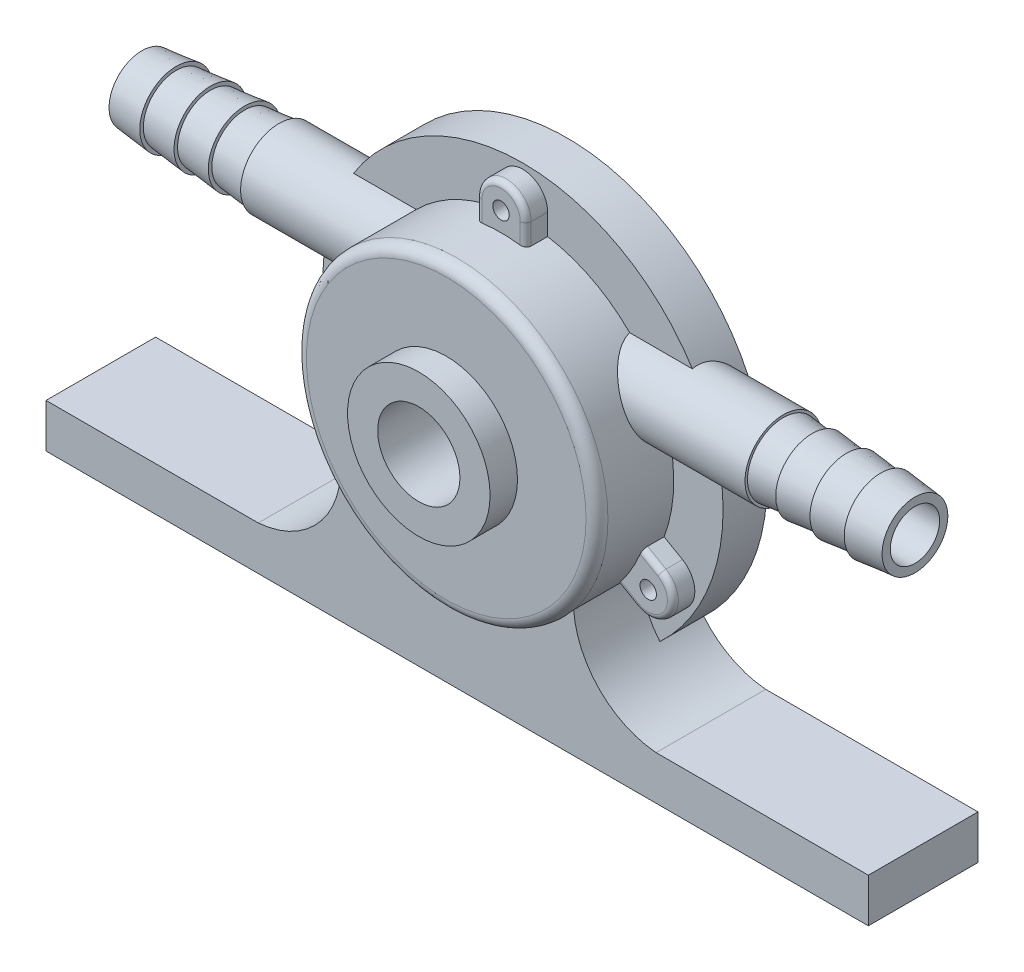
from build123d import *

# Parameters (mm, degrees)
SKETCH1_R                = 36.5
BOSS_EXTRUDE1_DEPTH      = 8
SKETCH2_R                = 27.5
BOSS_EXTRUDE2_DEPTH      = 14
SKETCH3_R                = 13
BOSS_EXTRUDE3_DEPTH      = 5
SKETCH4_R                = 7.5
CUT_EXTRUDE1_DEPTH       = 14
SKETCH6_R                = 7
BOSS_EXTRUDE4_DEPTH      = 10
BOSS_EXTRUDE4_DEPTH_BACK = 82
CUT_EXTRUDE2_DEPTH       = 12
SKETCH11_R               = 1.5
CUT_EXTRUDE4_DEPTH       = 28
FILLET1_R                = 2
SKETCH10_R               = 4.5
CUT_EXTRUDE5_DEPTH       = 93.0000001
SKETCH12_R               = 3.2
CUT_EXTRUDE6_DEPTH       = 14.0000001
SKETCH13_R               = 27.3
SKETCH13_R_2             = 25
CUT_EXTRUDE7_DEPTH       = 1.2
BOSS_EXTRUDE5_DEPTH      = 4
FILLET2_R                = 1
SKETCH15_R               = 1.5
CUT_EXTRUDE8_DEPTH       = 28
SKETCH16_W               = 25
SKETCH16_H               = 5.2
SKETCH17_R               = 4.5
CUT_EXTRUDE9_DEPTH       = 142
BOSS_EXTRUDE7_DEPTH      = 4
BOSS_EXTRUDE7_DEPTH_BACK = 16


with BuildPart() as part:
    # Sketch1 → Boss-Extrude1 (new body)
    with BuildSketch(Plane.XY):
        Circle(SKETCH1_R)
    extrude(amount=BOSS_EXTRUDE1_DEPTH)

    # Sketch2 → Boss-Extrude2 (add)
    with BuildSketch(Plane.XY.offset(8)):
        Circle(SKETCH2_R)
    extrude(amount=BOSS_EXTRUDE2_DEPTH)

    # Sketch3 → Boss-Extrude3 (add)
    with BuildSketch(Plane.XY.offset(22)):
        Circle(SKETCH3_R)
    extrude(amount=BOSS_EXTRUDE3_DEPTH)

    # Sketch4 → Cut-Extrude1 (cut)
    with BuildSketch(Plane.XY.offset(27)):
        Circle(SKETCH4_R)
    extrude(amount=-CUT_EXTRUDE1_DEPTH, mode=Mode.SUBTRACT)

    # Sketch6 → Boss-Extrude4 (add, two sides)
    with BuildSketch(Plane(origin=(36.5, 0, 0), x_dir=(0, 0, -1), z_dir=(1, 0, 0))) as boss_extrude4_sk:
        with Locations((-7, 12.5)):
            Circle(SKETCH6_R)
    extrude(amount=BOSS_EXTRUDE4_DEPTH)
    extrude(boss_extrude4_sk.sketch, amount=-BOSS_EXTRUDE4_DEPTH_BACK)

    # Sketch8 → Cut-Extrude2 (cut)
    with BuildSketch(Plane(origin=(0, 0, 0), x_dir=(-1, 0, 0), z_dir=(0, 0, -1))):
        with BuildLine():
            ThreePointArc((-17.653540721, 13.95), (0, -22.5), (17.653540721, 13.95))
            ThreePointArc((17.653540721, 13.95), (0, 18), (-17.653540721, 13.95))
        make_face()
    extrude(amount=-CUT_EXTRUDE2_DEPTH, mode=Mode.SUBTRACT)

    # Sketch11 → Cut-Extrude4 (cut, through all)
    with BuildSketch(Plane(origin=(0, 0, 0), x_dir=(-1, 0, 0), z_dir=(0, 0, -1))):
        with Locations((0, 31)):
            Circle(SKETCH11_R)
        with Locations((26.846787517, -15.5)):
            Circle(SKETCH11_R)
        with Locations((-26.846787517, -15.5)):
            Circle(SKETCH11_R)
    extrude(amount=-CUT_EXTRUDE4_DEPTH, mode=Mode.SUBTRACT)

    # Fillet1
    fillet1_edges = [part.edges().sort_by_distance(p)[0] for p in [
        (-27.5, 0, 22),
    ]]
    fillet(fillet1_edges, radius=FILLET1_R)

    # Sketch10 → Cut-Extrude5 (cut, through all)
    with BuildSketch(Plane(origin=(46.5, 0, 0), x_dir=(0, 0, -1), z_dir=(1, 0, 0))):
        with Locations((-7, 12.5)):
            Circle(SKETCH10_R)
    extrude(amount=-CUT_EXTRUDE5_DEPTH, mode=Mode.SUBTRACT)

    # Sketch12 → Cut-Extrude6 (cut, through all)
    with BuildSketch(Plane.XY.offset(13)):
        Circle(SKETCH12_R)
    extrude(amount=-CUT_EXTRUDE6_DEPTH, mode=Mode.SUBTRACT)

    # Sketch13 → Cut-Extrude7 (cut)
    with BuildSketch(Plane(origin=(0, 0, 0), x_dir=(-1, 0, 0), z_dir=(0, 0, -1))):
        Circle(SKETCH13_R)
        Circle(SKETCH13_R_2, mode=Mode.SUBTRACT)
    extrude(amount=-CUT_EXTRUDE7_DEPTH, mode=Mode.SUBTRACT)

    # Sketch14 → Boss-Extrude5 (add)
    with BuildSketch(Plane.XY.offset(8)):
        with BuildLine():
            Line((4.5, 31), (4.5, 27.129319933))
            ThreePointArc((4.5, 27.129319933), (0, 27.5), (-4.5, 27.129319933))
            Line((-4.5, 27.129319933), (-4.5, 31))
            ThreePointArc((-4.5, 31), (0, 35.5), (4.5, 31))
        make_face()
        with BuildLine():
            Line((29.096787517, -11.602885683), (25.744680249, -9.667545649))
            ThreePointArc((25.744680249, -9.667545649), (23.815698604, -13.75), (21.244680249, -17.461774283))
            Line((21.244680249, -17.461774283), (24.596787517, -19.397114317))
            ThreePointArc((24.596787517, -19.397114317), (30.743901834, -17.75), (29.096787517, -11.602885683))
        make_face()
        with BuildLine():
            Line((-24.596787517, -19.397114317), (-21.244680249, -17.461774283))
            ThreePointArc((-21.244680249, -17.461774283), (-23.815698604, -13.75), (-25.744680249, -9.667545649))
            Line((-25.744680249, -9.667545649), (-29.096787517, -11.602885683))
            ThreePointArc((-29.096787517, -11.602885683), (-30.743901834, -17.75), (-24.596787517, -19.397114317))
        make_face()
    extrude(amount=BOSS_EXTRUDE5_DEPTH)

    # Fillet2
    fillet2_edges = [part.edges().sort_by_distance(p)[0] for p in [
        (30.743901834, -17.75, 12),
        (27.420733883, -10.635215666, 12),
        (22.920733883, -18.4294443, 12),
        (-30.743901834, -17.75, 12),
        (-22.920733883, -18.4294443, 12),
        (-27.420733883, -10.635215666, 12),
        (0, 35.5, 12),
        (-4.5, 29.064659966, 12),
        (4.5, 29.064659966, 12),
    ]]
    fillet(fillet2_edges, radius=FILLET2_R)

    # Sketch15 → Cut-Extrude8 (cut, through all)
    with BuildSketch(Plane(origin=(0, 0, 0), x_dir=(-1, 0, 0), z_dir=(0, 0, -1))):
        with Locations((0, 31)):
            Circle(SKETCH15_R)
        with Locations((26.846787517, -15.5)):
            Circle(SKETCH15_R)
        with Locations((-26.846787517, -15.5)):
            Circle(SKETCH15_R)
    extrude(amount=-CUT_EXTRUDE8_DEPTH, mode=Mode.SUBTRACT)

    # Sketch16 → Revolve1 (revolve)
    with BuildSketch(Plane(origin=(0, 12.5, 0), x_dir=(1, 0, 0), z_dir=(0, 1, 0))):
        with Locations((-58, -9.6)):
            Rectangle(SKETCH16_W, SKETCH16_H)
        Polygon((-70.5, -12.2), (-70.5, -13), (-64.25, -13.65), (-64.25, -13), (-58, -13.65), (-58, -13), (-51.75, -13.65), (-51.75, -13), (-45.5, -13.65), (-45.5, -13), (-45.5, -12.2), align=None)
        Polygon((70.5, -13), (70.5, -7), (45.5, -7), (45.5, -13), (45.5, -13.65), (51.75, -13), (51.75, -13.65), (58, -13), (58, -13.65), (64.25, -13), (64.25, -13.65), align=None)
    revolve(axis=Axis((70.5, 12.5, 7), (-1, 0, 0)))

    # Sketch17 → Cut-Extrude9 (cut, through all)
    with BuildSketch(Plane(origin=(70.5, 0, 0), x_dir=(0, 0, -1), z_dir=(1, 0, 0))):
        with Locations((-7, 12.5)):
            Circle(SKETCH17_R)
    extrude(amount=-CUT_EXTRUDE9_DEPTH, mode=Mode.SUBTRACT)

    # Sketch18 → Boss-Extrude7 (add, two sides)
    with BuildSketch(Plane(origin=(0, 0, 4), x_dir=(-1, 0, 0), z_dir=(0, 0, -1))) as boss_extrude7_sk:
        with BuildLine():
            Line((-75, -32.5), (-36.282905966, -32.5))
            ThreePointArc((-36.282905966, -32.5), (-25.996296714, -27.748383535), (-21.244680249, -17.461774283))
            ThreePointArc((-21.244680249, -17.461774283), (0, -27.5), (21.244680249, -17.461774283))
            ThreePointArc((21.244680249, -17.461774283), (25.996296714, -27.748383535), (36.282905966, -32.5))
            Line((36.282905966, -32.5), (75, -32.5))
            Line((75, -32.5), (75, -40.5))
            Line((75, -40.5), (-75, -40.5))
            Line((-75, -40.5), (-75, -32.5))
        make_face()
    extrude(amount=BOSS_EXTRUDE7_DEPTH)
    extrude(boss_extrude7_sk.sketch, amount=-BOSS_EXTRUDE7_DEPTH_BACK)


solid = part.part
